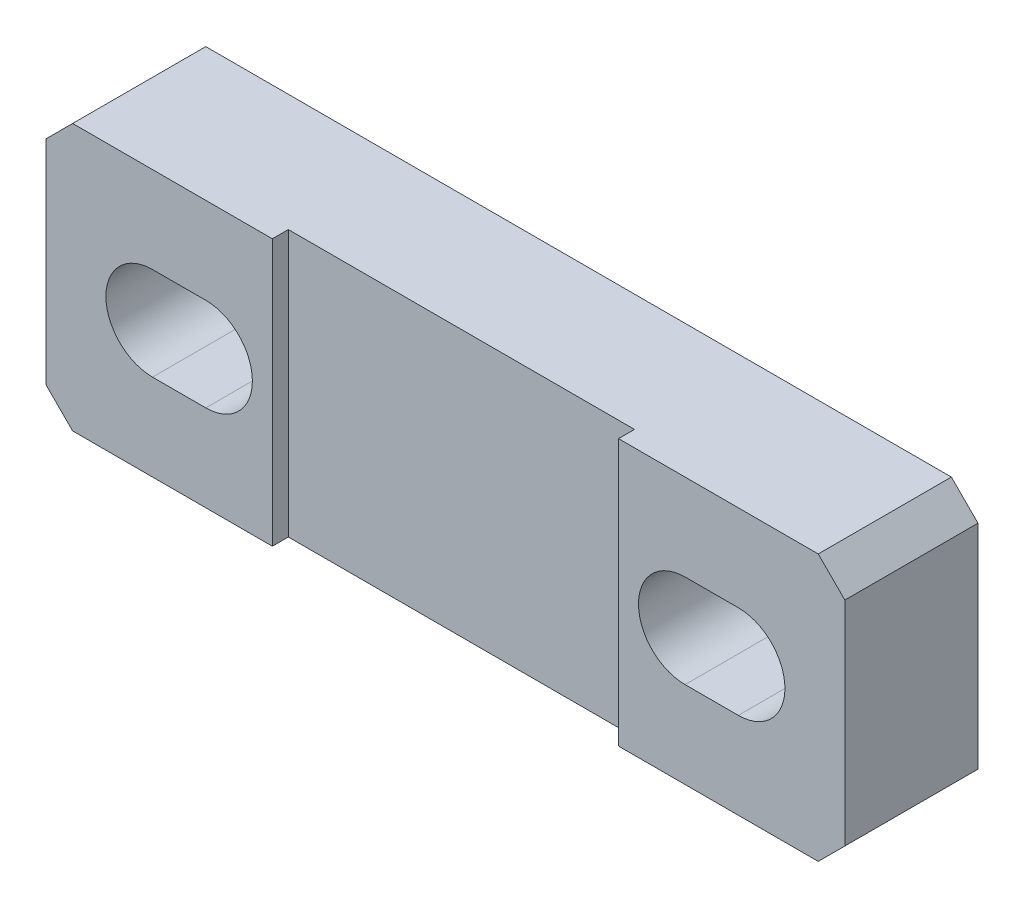
from build123d import *

# Parameters (mm, degrees)
SCHIZZO2_W                   = 30
SCHIZZO2_H                   = 10
ESTRUSIONE_ESTRUSIONE1_DEPTH = 5
SCHIZZO3_W                   = 13
SCHIZZO3_H                   = 10
TAGLIO_ESTRUSIONE1_DEPTH     = 0.6
SMUSSO1_SIZE                 = 1


with BuildPart() as part:
    # Schizzo2 → Estrusione-Estrusione1 (new body)
    with BuildSketch(Plane.XY):
        Rectangle(SCHIZZO2_W, SCHIZZO2_H)
        with BuildLine():
            Line((-9, -1.75), (-11, -1.75))
            ThreePointArc((-11, -1.75), (-12.75, 0), (-11, 1.75))
            Line((-11, 1.75), (-9, 1.75))
            ThreePointArc((-9, 1.75), (-7.25, 0), (-9, -1.75))
        make_face(mode=Mode.SUBTRACT)
        with BuildLine():
            Line((9, -1.75), (11, -1.75))
            ThreePointArc((11, -1.75), (12.75, 0), (11, 1.75))
            Line((11, 1.75), (9, 1.75))
            ThreePointArc((9, 1.75), (7.25, 0), (9, -1.75))
        make_face(mode=Mode.SUBTRACT)
    extrude(amount=-ESTRUSIONE_ESTRUSIONE1_DEPTH)

    # Schizzo3 → Taglio-Estrusione1 (cut)
    with BuildSketch(Plane.XY):
        Rectangle(SCHIZZO3_W, SCHIZZO3_H)
    extrude(amount=-TAGLIO_ESTRUSIONE1_DEPTH, mode=Mode.SUBTRACT)

    # Smusso1
    smusso1_edges = [part.edges().sort_by_distance(p)[0] for p in [
        (-15, 5, -2.5),
        (15, 5, -2.5),
        (15, -5, -2.5),
        (-15, -5, -2.5),
    ]]
    chamfer(smusso1_edges, length=SMUSSO1_SIZE)


solid = part.part
